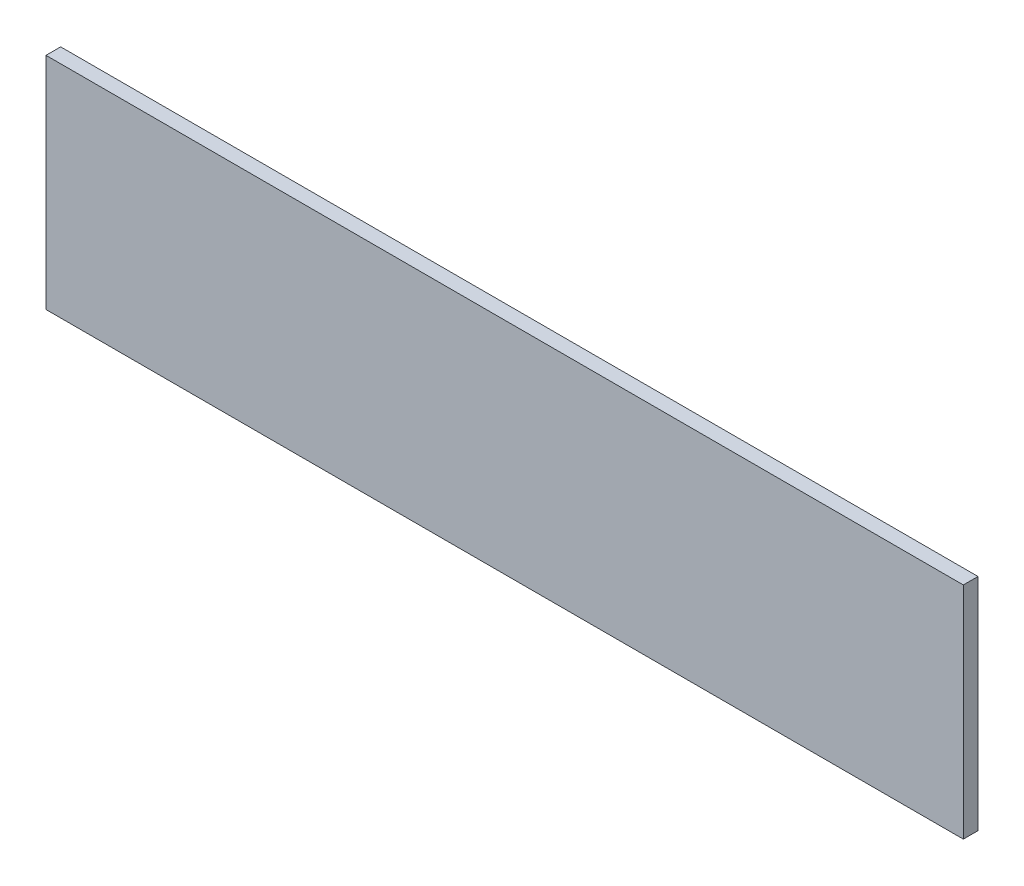
from build123d import *

# Parameters (mm, degrees)
SKETCH1_W           = 500
SKETCH1_H           = 120
BOSS_EXTRUDE1_DEPTH = 8


with BuildPart() as part:
    # Sketch1 → Boss-Extrude1 (new body)
    with BuildSketch(Plane.XY):
        Rectangle(SKETCH1_W, SKETCH1_H)
    extrude(amount=BOSS_EXTRUDE1_DEPTH)


solid = part.part
